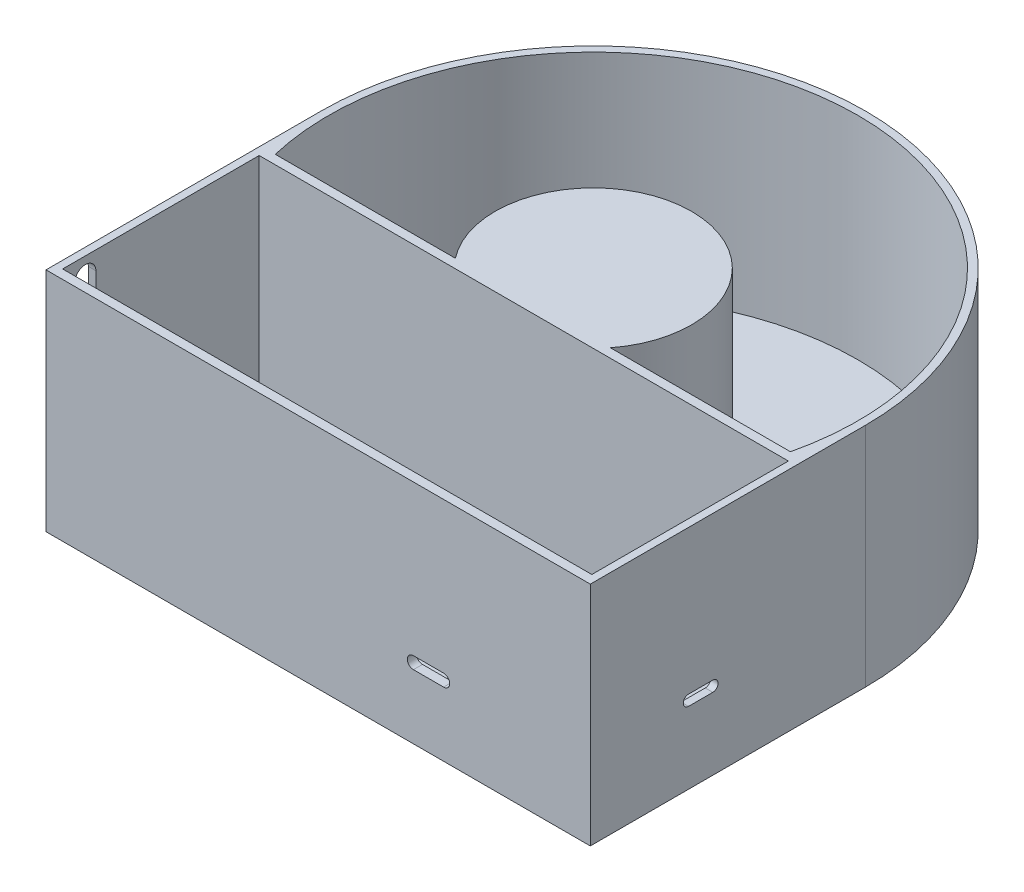
from build123d import *

# Parameters (mm, degrees)
SKETCH1_R           = 90
BOSS_EXTRUDE1_DEPTH = 75
SKETCH2_R           = 87.5
CUT_EXTRUDE1_DEPTH  = 70
SKETCH3_R           = 32.5
BOSS_EXTRUDE2_DEPTH = 70
SKETCH4_W           = 180
SKETCH4_H           = 66
CUT_EXTRUDE2_DEPTH  = 75
SKETCH5_W           = 175
SKETCH5_H           = 61.187525855
CUT_EXTRUDE3_DEPTH  = 75
SKETCH6_W           = 179.999459639
SKETCH6_H           = 83.811872958
CUT_EXTRUDE4_DEPTH  = 75
SKETCH8_W           = 180
SKETCH8_H           = 71
BOSS_EXTRUDE5_DEPTH = 75
BOSS_EXTRUDE6_REACH = 182
SKETCH10_W          = 20
SKETCH10_H          = 75
BOSS_EXTRUDE7_REACH = 182
SKETCH11_W          = 20
SKETCH11_H          = 75
SKETCH12_W          = 175
SKETCH12_H          = 65
CUT_EXTRUDE5_DEPTH  = 70
CUT_EXTRUDE6_DEPTH  = 70
CUT_EXTRUDE7_DEPTH  = 10
BOSS_EXTRUDE8_DEPTH = 50
CUT_EXTRUDE8_DEPTH  = 50


with BuildPart() as part:
    # Sketch1 → Boss-Extrude1 (new body)
    with BuildSketch(Plane(origin=(0, 0, 0), x_dir=(1, 0, 0), z_dir=(0, 1, 0))):
        Circle(SKETCH1_R)
    extrude(amount=BOSS_EXTRUDE1_DEPTH)

    # Sketch2 → Cut-Extrude1 (cut)
    with BuildSketch(Plane(origin=(0, 75, 0), x_dir=(1, 0, 0), z_dir=(0, 1, 0))):
        Circle(SKETCH2_R)
    extrude(amount=-CUT_EXTRUDE1_DEPTH, mode=Mode.SUBTRACT)

    # Sketch3 → Boss-Extrude2 (add)
    with BuildSketch(Plane(origin=(0, 5, 0), x_dir=(1, 0, 0), z_dir=(0, 1, 0))):
        Circle(SKETCH3_R)
    extrude(amount=BOSS_EXTRUDE2_DEPTH)

    # Sketch4 → Cut-Extrude2 (cut)
    with BuildSketch(Plane(origin=(0, 75, 0), x_dir=(1, 0, 0), z_dir=(0, 1, 0))):
        with Locations((0, -65.5)):
            Rectangle(SKETCH4_W, SKETCH4_H)
    extrude(amount=-CUT_EXTRUDE2_DEPTH, mode=Mode.SUBTRACT)

    # Sketch5 → Cut-Extrude3 (cut)
    with BuildSketch(Plane(origin=(0, 75, 0), x_dir=(1, 0, 0), z_dir=(0, 1, 0))):
        with Locations((-0.249643874, -50.593762928)):
            Rectangle(SKETCH5_W, SKETCH5_H)
    extrude(amount=-CUT_EXTRUDE3_DEPTH, mode=Mode.SUBTRACT)

    # Sketch6 → Cut-Extrude4 (cut)
    with BuildSketch(Plane(origin=(0, 75, 0), x_dir=(1, 0, 0), z_dir=(0, 1, 0))):
        with Locations((0.00027018, -61.905936479)):
            Rectangle(SKETCH6_W, SKETCH6_H)
    extrude(amount=-CUT_EXTRUDE4_DEPTH, mode=Mode.SUBTRACT)

    # Sketch8 → Boss-Extrude5 (add)
    with BuildSketch(Plane(origin=(0, 75, 0), x_dir=(1, 0, 0), z_dir=(0, 1, 0))):
        with Locations((0, -55.5)):
            Rectangle(SKETCH8_W, SKETCH8_H)
    extrude(amount=-BOSS_EXTRUDE5_DEPTH)

    # Sketch10 → Boss-Extrude6 (add, up to next)
    with BuildSketch(Plane.ZY.offset(90), mode=Mode.PRIVATE) as boss_extrude6_sk1:
        with Locations((10, 37.5)):
            Rectangle(SKETCH10_W, SKETCH10_H)
    boss_extrude6_tool1 = extrude(boss_extrude6_sk1.sketch, amount=-BOSS_EXTRUDE6_REACH, mode=Mode.PRIVATE) - part.part
    add(boss_extrude6_tool1.solids().sort_by_distance((-90, 37.5, 10))[0])

    # Sketch11 → Boss-Extrude7 (add, up to next)
    with BuildSketch(Plane(origin=(90, 0, 0), x_dir=(0, 0, -1), z_dir=(1, 0, 0)), mode=Mode.PRIVATE) as boss_extrude7_sk1:
        with Locations((-10, 37.5)):
            Rectangle(SKETCH11_W, SKETCH11_H)
    boss_extrude7_tool1 = extrude(boss_extrude7_sk1.sketch, amount=-BOSS_EXTRUDE7_REACH, mode=Mode.PRIVATE) - part.part
    add(boss_extrude7_tool1.solids().sort_by_distance((90, 37.5, 10))[0])

    # Sketch12 → Cut-Extrude5 (cut)
    with BuildSketch(Plane(origin=(0, 75, 0), x_dir=(1, 0, 0), z_dir=(0, 1, 0))):
        with Locations((0, -55.5)):
            Rectangle(SKETCH12_W, SKETCH12_H)
    extrude(amount=-CUT_EXTRUDE5_DEPTH, mode=Mode.SUBTRACT)

    # Sketch13 → Cut-Extrude6 (cut)
    with BuildSketch(Plane.ZY.offset(-87.5)):
        with BuildLine():
            Line((50.5, 27.25), (58.5, 27.25))
            ThreePointArc((58.5, 27.25), (60.25, 25.5), (58.5, 23.75))
            Line((58.5, 23.75), (50.5, 23.75))
            ThreePointArc((50.5, 23.75), (48.75, 25.5), (50.5, 27.25))
        make_face()
    extrude(amount=-CUT_EXTRUDE6_DEPTH, mode=Mode.SUBTRACT)

    # Sketch14 → Cut-Extrude7 (cut)
    with BuildSketch(Plane.XY.offset(91)):
        with BuildLine():
            Line((41.5, 21.25), (31.5, 21.25))
            ThreePointArc((31.5, 21.25), (29.5, 23.25), (31.5, 25.25))
            Line((31.5, 25.25), (41.5, 25.25))
            ThreePointArc((41.5, 25.25), (43.5, 23.25), (41.5, 21.25))
        make_face()
    extrude(amount=-CUT_EXTRUDE7_DEPTH, mode=Mode.SUBTRACT)

    # Sketch15 → Boss-Extrude8 (add)
    with BuildSketch(Plane(origin=(0, 0, 20), x_dir=(-1, 0, 0), z_dir=(0, 0, -1))):
        Polygon((55.400501051, 5), (57.12123036, 7.457456133), (56.12123036, 7.457456133), (54.400501051, 5), align=None)
        Polygon((73.679771742, 7.457456133), (74.679771742, 7.457456133), (76.400501051, 5), (75.400501051, 5), align=None)
    extrude(amount=BOSS_EXTRUDE8_DEPTH)

    # Sketch17 → Cut-Extrude8 (cut)
    with BuildSketch(Plane.ZY.offset(90)):
        with BuildLine():
            Line((84, 69), (84, 54))
            ThreePointArc((84, 54), (80.5, 50.5), (77, 54))
            Line((77, 54), (77, 69))
            ThreePointArc((77, 69), (80.5, 72.5), (84, 69))
        make_face()
    extrude(amount=-CUT_EXTRUDE8_DEPTH, mode=Mode.SUBTRACT)


solid = part.part
